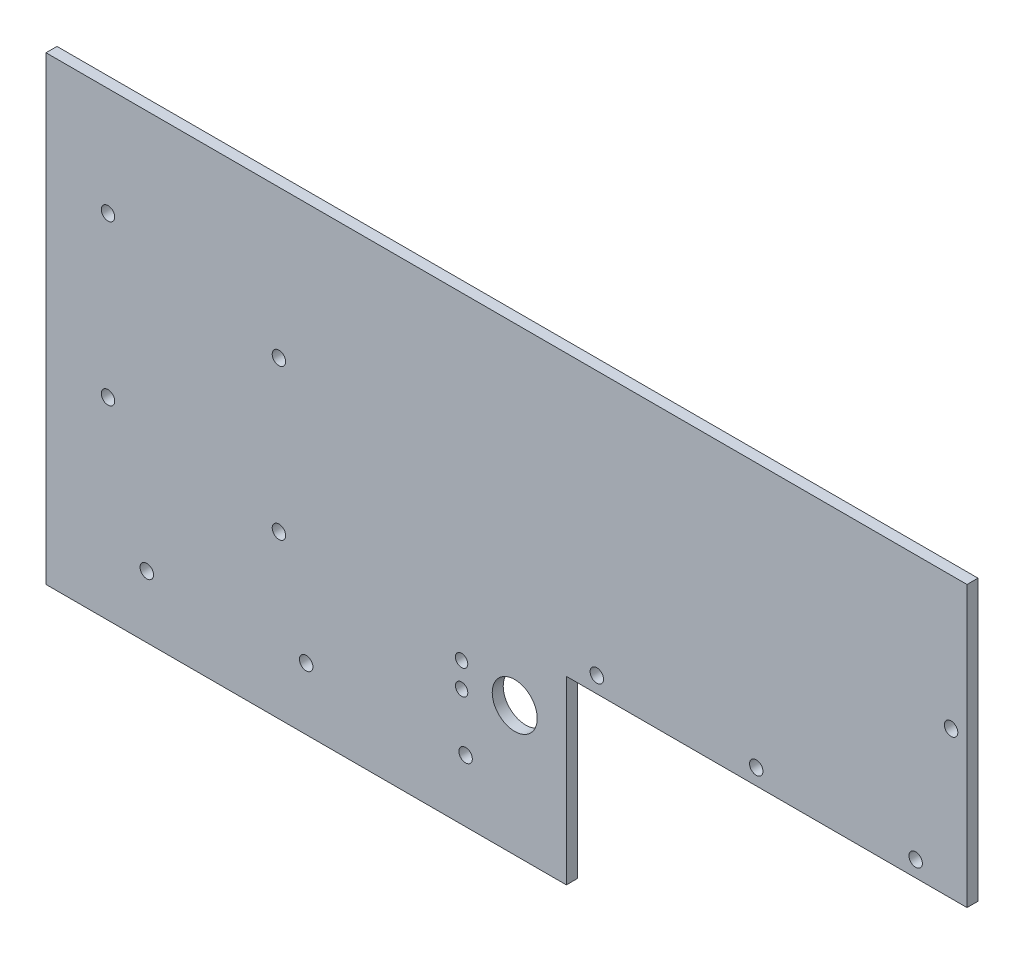
from build123d import *

# Parameters (mm, degrees)
BOSS_EXTRUDE1_DEPTH   = 3.1
F_6_CLEARANCE_HOLE1_D = 3.7973
F_6_CLEARANCE_HOLE2_D = 3.7973
SKETCH8_R             = 6.35
SKETCH8_R_2           = 1.75
CUT_EXTRUDE1_DEPTH    = 4.1


with BuildPart() as part:
    # Sketch1 → Boss-Extrude1 (new body)
    with BuildSketch(Plane.XY):
        Polygon((130, -14), (16.9, -14), (16.9, -65), (-130, -65), (-130, 65), (130, 65), align=None)
    extrude(amount=BOSS_EXTRUDE1_DEPTH)

    # #6 Clearance Hole1 (through all)
    with Locations(Plane.XY.offset(3.1)):
        with Locations((25.5, -9.5), (70.5, -9.5), (115.5, -9.5), (-11.54975, -47.5), (-56.54975, -47.5), (-101.54975, -47.5), (125.5, 27.5), (-64.244394137, -19.232770082), (-64.244394137, 23.267229918)):
            Hole(F_6_CLEARANCE_HOLE1_D / 2)

    # #6 Clearance Hole2 (through all)
    with Locations(Plane.XY.offset(3.1)):
        with Locations((-112.4995, 34.5024), (-112.4995, -10.4976)):
            Hole(F_6_CLEARANCE_HOLE2_D / 2)

    # Sketch8 → Cut-Extrude1 (cut, through all)
    with BuildSketch(Plane(origin=(0, 0, 0), x_dir=(-1, 0, 0), z_dir=(0, 0, -1))):
        with Locations((-2.31737005, -28.419585766)):
            Circle(SKETCH8_R)
        with Locations((12.68262995, -24.919585766)):
            Circle(SKETCH8_R_2)
        with Locations((12.68262995, -31.919585766)):
            Circle(SKETCH8_R_2)
    extrude(amount=-CUT_EXTRUDE1_DEPTH, mode=Mode.SUBTRACT)


solid = part.part
